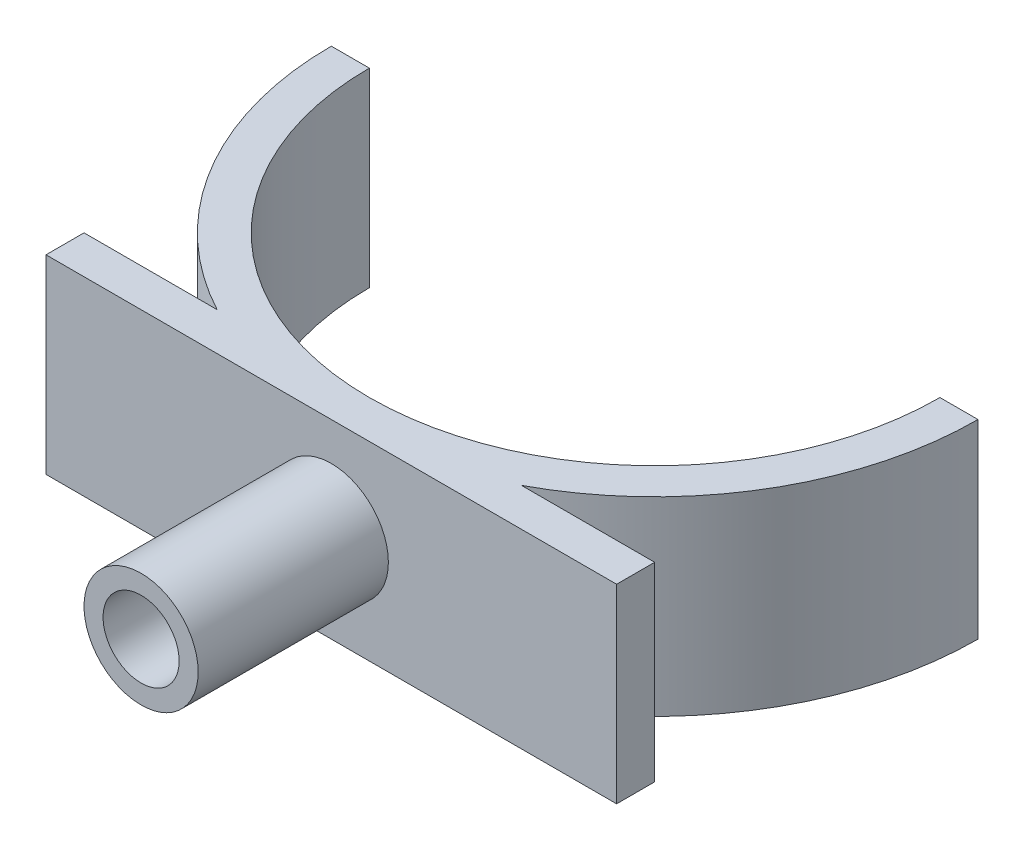
from build123d import *

# Parameters (mm, degrees)
SKETCH1_R                = 3
SKETCH1_R_2              = 2
BOSS_EXTRUDE1_DEPTH      = 10
BOSS_EXTRUDE2_DEPTH      = 2
BOSS_EXTRUDE3_DEPTH      = 5
BOSS_EXTRUDE3_DEPTH_BACK = 5


with BuildPart() as part:
    # Sketch1 → Boss-Extrude1 (new body)
    with BuildSketch(Plane.XY):
        Circle(SKETCH1_R)
        Circle(SKETCH1_R_2, mode=Mode.SUBTRACT)
    extrude(amount=BOSS_EXTRUDE1_DEPTH)

    # Sketch2 → Boss-Extrude2 (add)
    with BuildSketch(Plane(origin=(0, 0, 0), x_dir=(-1, 0, 0), z_dir=(0, 0, -1))):
        Polygon((0, 5), (15, 5), (15, -5), (-15, -5), (-15, 5), align=None)
    extrude(amount=BOSS_EXTRUDE2_DEPTH)

    # Sketch4 → Boss-Extrude3 (add, two sides: drawn at the far end of the back side and taken through both)
    with BuildSketch(Plane(origin=(0, 0, 0), x_dir=(1, 0, 0), z_dir=(0, 1, 0)).offset(-BOSS_EXTRUDE3_DEPTH_BACK)):
        with BuildLine():
            ThreePointArc((-17, 17), (-14.577379737, 8.253572158), (-8, 2))
            Line((-8, 2), (-2.6e-08, 2))
            ThreePointArc((-2.6e-08, 2), (-10.606601727, 6.393398292), (-15, 17))
            Line((-15, 17), (-17, 17))
        make_face()
        with BuildLine():
            ThreePointArc((15, 17), (10.606601708, 6.393398273), (-2.6e-08, 2))
            Line((-2.6e-08, 2), (8, 2))
            ThreePointArc((8, 2), (14.577379737, 8.253572158), (17, 17))
            Line((17, 17), (15, 17))
        make_face()
    extrude(amount=BOSS_EXTRUDE3_DEPTH + BOSS_EXTRUDE3_DEPTH_BACK)


solid = part.part
